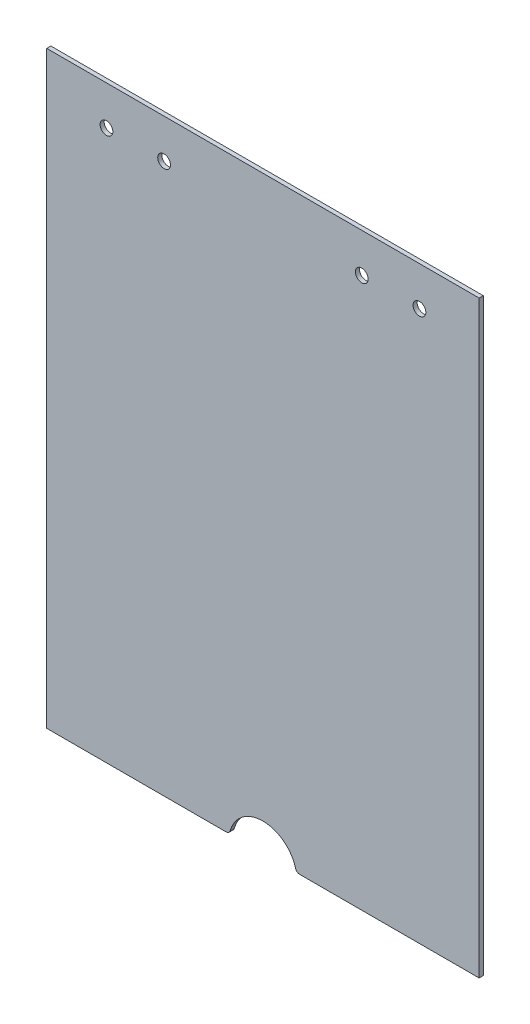
from build123d import *

# Parameters (mm, degrees)
SKETCH_1_R      = 1.55
EXTRUDE_1_DEPTH = 1


with BuildPart() as part:
    # 草图1 → 凸台-拉伸1 (new body)
    with BuildSketch(Plane.XY):
        with BuildLine():
            Line((8.920204993, -71.5), (52.5, -71.5))
            Line((52.5, -71.5), (52.5, 71.5))
            Line((52.5, 71.5), (-52.5, 71.5))
            Line((-52.5, 71.5), (-52.5, -71.5))
            Line((-52.5, -71.5), (-8.920204993, -71.5))
            ThreePointArc((-8.920204993, -71.5), (-8.315996588, -71.296826332), (-7.957306659, -70.769864407))
            ThreePointArc((-7.957306659, -70.769864407), (0, -64.736088455), (7.957306659, -70.769864407))
            ThreePointArc((7.957306659, -70.769864407), (8.315996588, -71.296826332), (8.920204993, -71.5))
        make_face()
        with Locations((-38, 62)):
            Circle(SKETCH_1_R, mode=Mode.SUBTRACT)
        with Locations((-24, 62)):
            Circle(SKETCH_1_R, mode=Mode.SUBTRACT)
        with Locations((24, 62)):
            Circle(SKETCH_1_R, mode=Mode.SUBTRACT)
        with Locations((38, 62)):
            Circle(SKETCH_1_R, mode=Mode.SUBTRACT)
    extrude(amount=EXTRUDE_1_DEPTH)


solid = part.part
